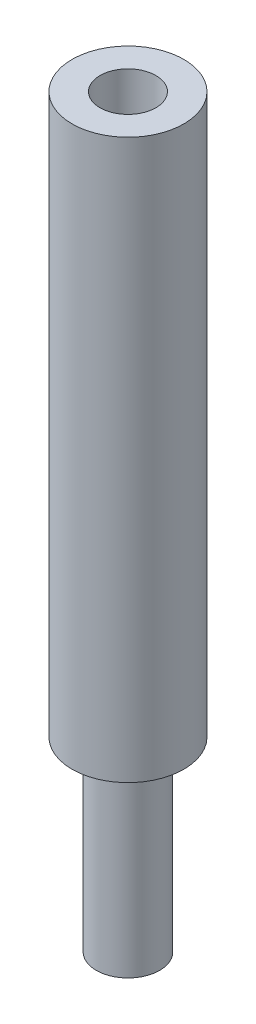
from build123d import *

# Parameters (mm, degrees)
SKETCH1_R           = 1.7
BOSS_EXTRUDE1_DEPTH = 10
SKETCH2_R           = 3
BOSS_EXTRUDE2_DEPTH = 30
SKETCH3_R           = 1.5
CUT_EXTRUDE1_DEPTH  = 8


with BuildPart() as part:
    # Sketch1 → Boss-Extrude1 (new body)
    with BuildSketch(Plane(origin=(0, 0, 0), x_dir=(1, 0, 0), z_dir=(0, 1, 0))):
        Circle(SKETCH1_R)
    extrude(amount=BOSS_EXTRUDE1_DEPTH)

    # Sketch2 → Boss-Extrude2 (add)
    with BuildSketch(Plane(origin=(0, 10, 0), x_dir=(1, 0, 0), z_dir=(0, 1, 0))):
        Circle(SKETCH2_R)
    extrude(amount=BOSS_EXTRUDE2_DEPTH)

    # Sketch3 → Cut-Extrude1 (cut)
    with BuildSketch(Plane(origin=(0, 40, 0), x_dir=(1, 0, 0), z_dir=(0, 1, 0))):
        Circle(SKETCH3_R)
    extrude(amount=-CUT_EXTRUDE1_DEPTH, mode=Mode.SUBTRACT)


solid = part.part
